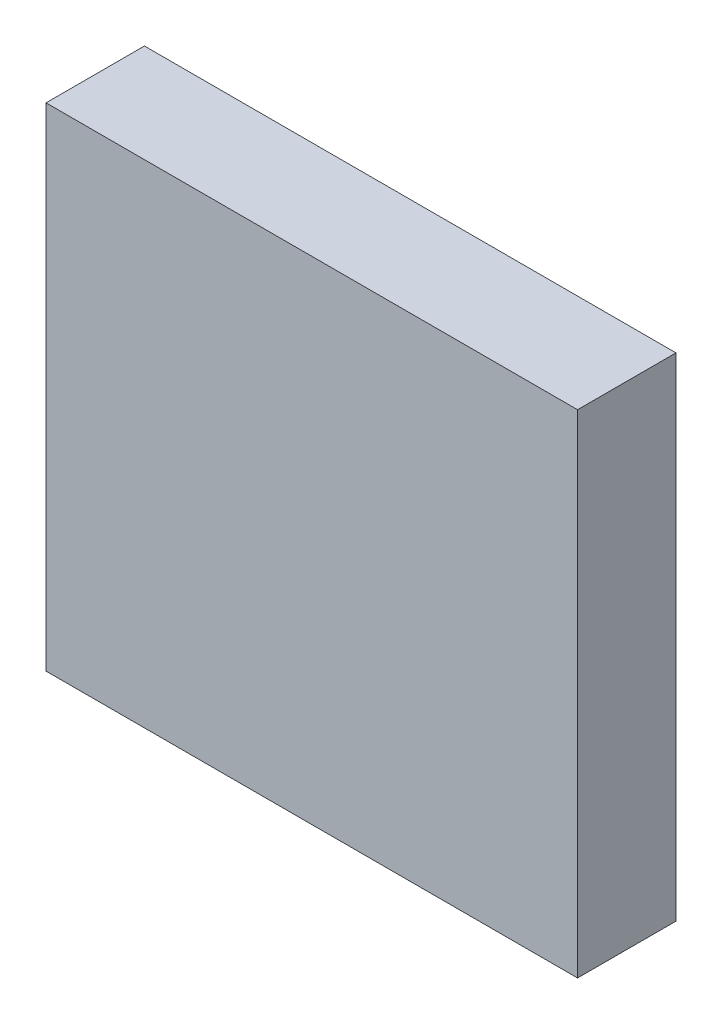
from build123d import *

# Parameters (mm, degrees)
ESQUISSE1_W        = 270
ESQUISSE1_H        = 250
BOSS_EXTRU_1_DEPTH = 50


with BuildPart() as part:
    # Esquisse1 → Boss.-Extru.1 (new body)
    with BuildSketch(Plane.XY):
        Rectangle(ESQUISSE1_W, ESQUISSE1_H)
    extrude(amount=BOSS_EXTRU_1_DEPTH)


solid = part.part
